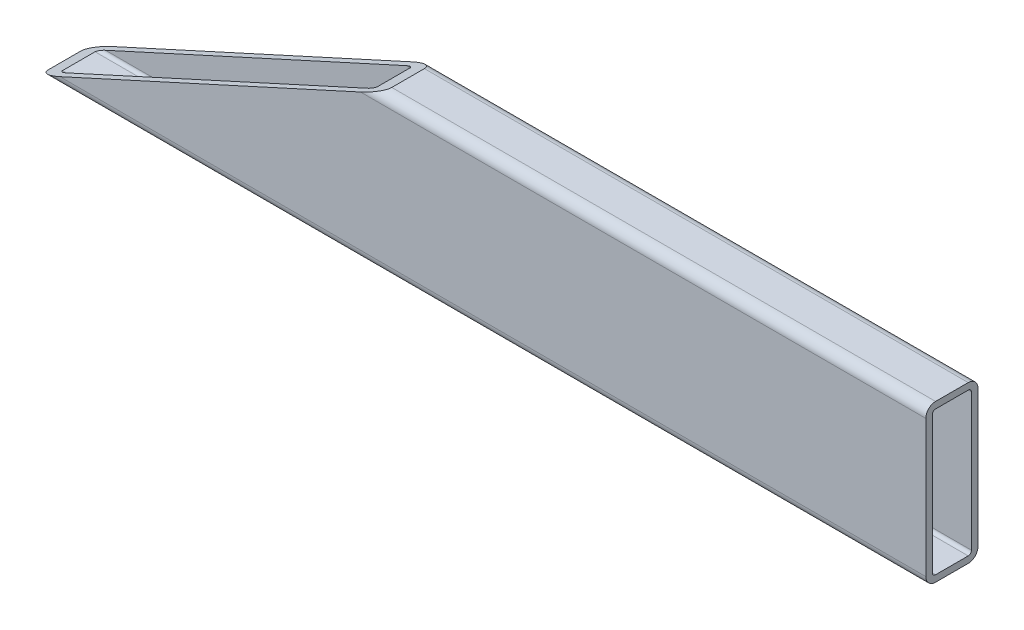
from build123d import *

# Parameters (mm, degrees)
RECTANGULAR_TUBE_3_X_2_X_0_25_1_DEPTH = 431.8
CUT_EXTRUDE1_DEPTH                    = 221.702469402


with BuildPart() as part:
    # Sketch13 → Rectangular tube 3 X 2 X 0.25(1) (new body)
    with BuildSketch(Plane.ZY.offset(-215.9)):
        with BuildLine():
            Line((-7.9375, -38.1), (7.9375, -38.1))
            ThreePointArc((7.9375, -38.1), (11.305096045, -36.705096045), (12.7, -33.3375))
            Line((12.7, -33.3375), (12.7, 33.3375))
            ThreePointArc((12.7, 33.3375), (11.305096045, 36.705096045), (7.9375, 38.1))
            Line((7.9375, 38.1), (-7.9375, 38.1))
            ThreePointArc((-7.9375, 38.1), (-11.305096045, 36.705096045), (-12.7, 33.3375))
            Line((-12.7, 33.3375), (-12.7, -33.3375))
            ThreePointArc((-12.7, -33.3375), (-11.305096045, -36.705096045), (-7.9375, -38.1))
        make_face()
        with BuildLine():
            Line((-7.9375, -34.925), (7.9375, -34.925))
            ThreePointArc((7.9375, -34.925), (9.060032015, -34.460032015), (9.525, -33.3375))
            Line((9.525, -33.3375), (9.525, 33.3375))
            ThreePointArc((9.525, 33.3375), (9.060032015, 34.460032015), (7.9375, 34.925))
            Line((7.9375, 34.925), (-7.9375, 34.925))
            ThreePointArc((-7.9375, 34.925), (-9.060032015, 34.460032015), (-9.525, 33.3375))
            Line((-9.525, 33.3375), (-9.525, -33.3375))
            ThreePointArc((-9.525, -33.3375), (-9.060032015, -34.460032015), (-7.9375, -34.925))
        make_face(mode=Mode.SUBTRACT)
    extrude(amount=RECTANGULAR_TUBE_3_X_2_X_0_25_1_DEPTH)

    # s → Cut-Extrude1 (cut, through all)
    with BuildSketch(Plane.XY.offset(12.7)):
        Polygon((-215.9, -38.1), (-215.9, 38.1), (-48.694360485, 38.1), align=None)
    extrude(amount=-CUT_EXTRUDE1_DEPTH, mode=Mode.SUBTRACT)


solid = part.part
